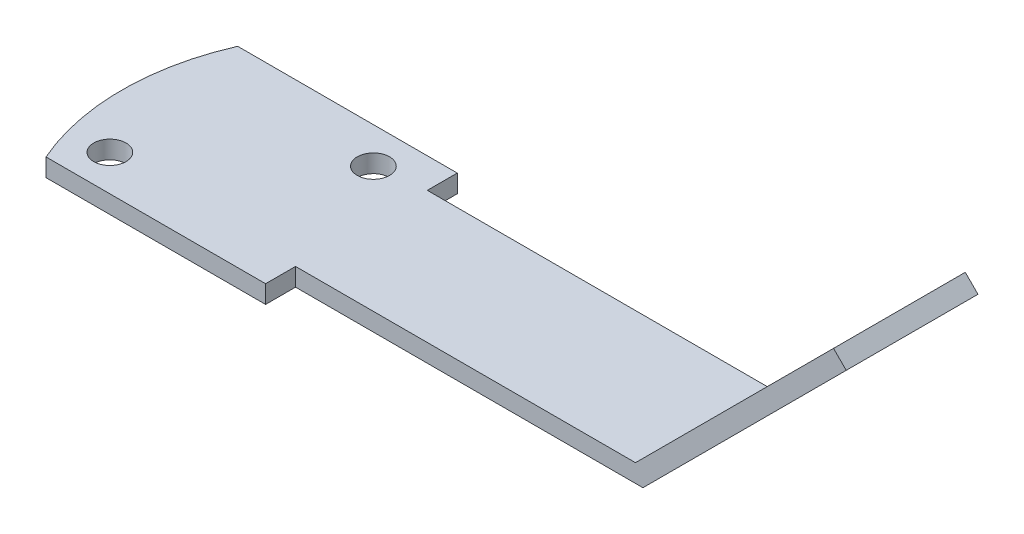
from build123d import *

# Parameters (mm, degrees)
MAIN_BODY_SKETCH_W            = 29
MAIN_BODY_SKETCH_H            = 11
MAIN_BODY_EXTRUDE_DEPTH       = 1.5
TILTED_OFFSHOOT_SKETCH_W      = 11
TILTED_OFFSHOOT_SKETCH_H      = 24
TILTED_OFFSHOOT_EXTRUDE_DEPTH = 1.5
F_2_7_2_7_DIAMETER_HOLE1_D    = 2.7
F_3_0_3_DIAMETER_HOLE1_D      = 3


with BuildPart() as part:
    # Main Body Sketch → Main Body Extrude (new body)
    with BuildSketch(Plane(origin=(0, 0, 0), x_dir=(1, 0, 0), z_dir=(0, 1, 0))):
        Polygon((-29, -11), (-29, 0), (-29, 2.5), (-47.33030278, 2.5), (-47.33030278, -13.5), (-29, -13.5), align=None)
        with Locations((-14.5, -5.5)):
            Rectangle(MAIN_BODY_SKETCH_W, MAIN_BODY_SKETCH_H)
        with BuildLine():
            ThreePointArc((-47.33030278, -13.5), (-49, -5.5), (-47.33030278, 2.5))
            Line((-47.33030278, 2.5), (-47.33030278, -13.5))
        make_face()
    extrude(amount=MAIN_BODY_EXTRUDE_DEPTH)

    # Tilted Offshoot Sketch → Tilted Offshoot Extrude (add)
    with BuildSketch(Plane(origin=(0, 0, 0), x_dir=(0, 0, 1), z_dir=(-0.707106781, 0.707106781, 0))):
        with Locations((5.5, 12)):
            Rectangle(TILTED_OFFSHOOT_SKETCH_W, TILTED_OFFSHOOT_SKETCH_H)
    extrude(amount=TILTED_OFFSHOOT_EXTRUDE_DEPTH)

    # Ø2.7 (2.7) Diameter Hole1 (through all)
    with Locations(Plane(origin=(0, 1.5, 0), x_dir=(1, 0, 0), z_dir=(0, 1, 0))):
        with Locations((-45, -10.5), (-33, -0.5)):
            Hole(F_2_7_2_7_DIAMETER_HOLE1_D / 2)

    # Ø3.0 (3) Diameter Hole1 (through all)
    with Locations(Plane(origin=(-1.060660172, 1.060660172, 0), x_dir=(0.707106781, 0.707106781, 0), z_dir=(-0.707106781, 0.707106781, 0))):
        with Locations((20, -5.5)):
            Hole(F_3_0_3_DIAMETER_HOLE1_D / 2)


solid = part.part
